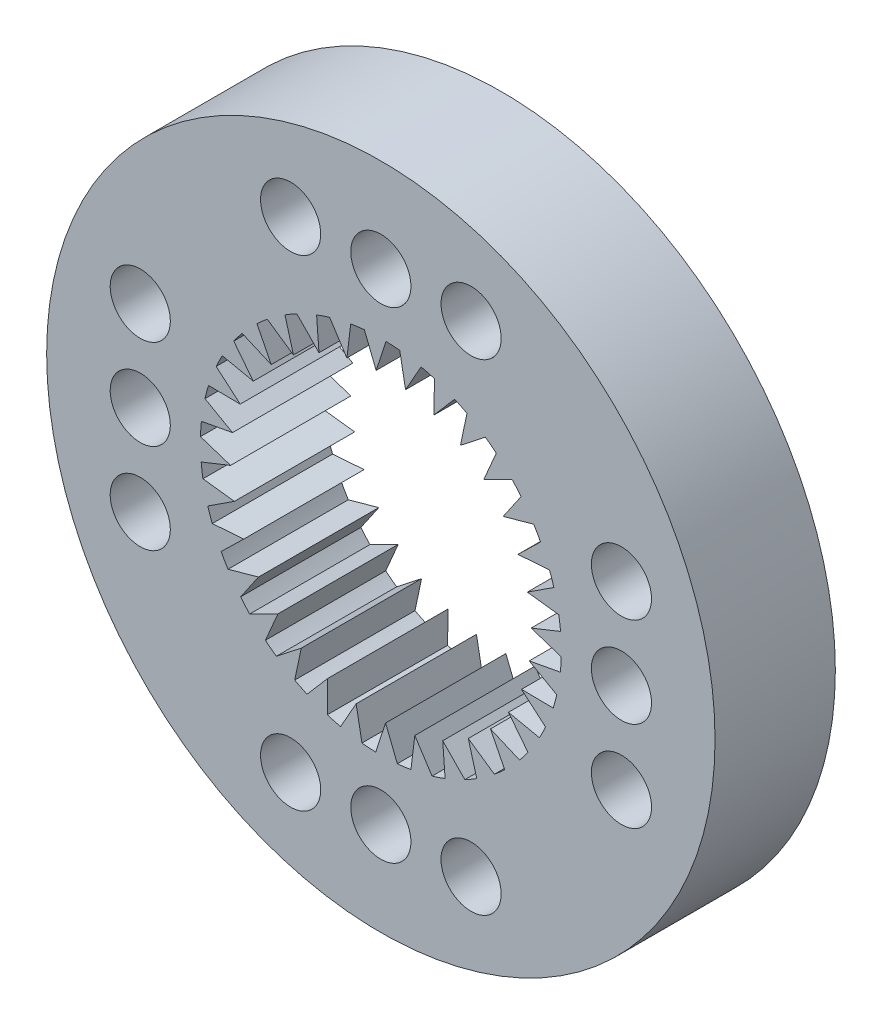
from build123d import *

# Parameters (mm, degrees)
SKETCH1_R          = 5.55625
EXTRUDE1_DEPTH     = 2
SKETCH2_R          = 0.5
CUT_EXTRUDE1_DEPTH = 2
CIRPATTERN1_COUNT  = 4
CUT_EXTRUDE2_DEPTH = 2


with BuildPart() as part:
    # Sketch1 → Extrude1 (new body)
    with BuildSketch(Plane.XY):
        Circle(SKETCH1_R)
    extrude(amount=EXTRUDE1_DEPTH)

    # Sketch2 → Cut-Extrude1 (cut)
    with BuildSketch(Plane.XY.offset(2)):
        with Locations((-1.5, 4)):
            Circle(SKETCH2_R)
        with Locations((0, 4)):
            Circle(SKETCH2_R)
        with Locations((1.5, 4)):
            Circle(SKETCH2_R)
    cut_extrude1 = extrude(amount=-CUT_EXTRUDE1_DEPTH, mode=Mode.SUBTRACT)

    # CirPattern1: Cut-Extrude1 ×4 about axis
    cirpattern1_axis = Axis((0, 0, 0), (0, 0, 1))
    for i in range(1, CIRPATTERN1_COUNT):
        add(cut_extrude1.rotate(cirpattern1_axis, i * 360 / CIRPATTERN1_COUNT), mode=Mode.SUBTRACT)

    # Sketch3 → Cut-Extrude2 (cut)
    with BuildSketch(Plane(origin=(0, 0, 0), x_dir=(-1, 0, 0), z_dir=(0, 0, -1))):
        with BuildLine():
            Line((2.655233037, -1.396330018), (2.278530277, -1.02873698))
            Line((2.278530277, -1.02873698), (2.803385583, -1.068189718))
            ThreePointArc((2.803385583, -1.068189718), (2.842070866, -0.960537971), (2.876623952, -0.85148966))
            Line((2.876623952, -0.85148966), (2.435445586, -0.564450882))
            Line((2.435445586, -0.564450882), (2.957912791, -0.500751356))
            ThreePointArc((2.957912791, -0.500751356), (2.974852933, -0.387620982), (2.987467821, -0.273927032))
            Line((2.987467821, -0.273927032), (2.498768086, -0.078473253))
            Line((2.498768086, -0.078473253), (2.998769069, 0.0859306))
            ThreePointArc((2.998769069, 0.0859306), (2.99331307, 0.200192063), (2.983504977, 0.314162459))
            Line((2.983504977, 0.314162459), (2.46606433, 0.410520059))
            Line((2.46606433, 0.410520059), (2.924384334, 0.669310291))
            ThreePointArc((2.924384334, 0.669310291), (2.896741865, 0.780311839), (2.864887711, 0.890178862))
            Line((2.864887711, 0.890178862), (2.338591105, 0.883737315))
            Line((2.338591105, 0.883737315), (2.737617149, 1.226968763))
            ThreePointArc((2.737617149, 1.226968763), (2.688850494, 1.330444669), (2.636174416, 1.431986191))
            Line((2.636174416, 1.431986191), (2.121247135, 1.322993042))
            Line((2.121247135, 1.322993042), (2.445644872, 1.737475514))
            ThreePointArc((2.445644872, 1.737475514), (2.377628107, 1.829449257), (2.306154417, 1.918763093))
            Line((2.306154417, 1.918763093), (1.822384828, 1.711406889))
            Line((1.822384828, 1.711406889), (2.059687834, 2.181212054))
            ThreePointArc((2.059687834, 2.181212054), (1.975034805, 2.258149136), (1.887510196, 2.331803006))
            Line((1.887510196, 2.331803006), (1.453489293, 2.034052328))
            Line((1.453489293, 2.034052328), (1.594578148, 2.541125839))
            ThreePointArc((1.594578148, 2.541125839), (1.496542023, 2.600069609), (1.396330018, 2.655233037))
            Line((1.396330018, 2.655233037), (1.02873698, 2.278530277))
            Line((1.02873698, 2.278530277), (1.068189718, 2.803385583))
            ThreePointArc((1.068189718, 2.803385583), (0.960537971, 2.842070866), (0.85148966, 2.876623952))
            Line((0.85148966, 2.876623952), (0.564450882, 2.435445586))
            Line((0.564450882, 2.435445586), (0.500751356, 2.957912791))
            ThreePointArc((0.500751356, 2.957912791), (0.387620982, 2.974852933), (0.273927032, 2.987467821))
            Line((0.273927032, 2.987467821), (0.078473253, 2.498768086))
            Line((0.078473253, 2.498768086), (-0.0859306, 2.998769069))
            ThreePointArc((-0.0859306, 2.998769069), (-0.200192063, 2.99331307), (-0.314162459, 2.983504977))
            Line((-0.314162459, 2.983504977), (-0.410520059, 2.46606433))
            Line((-0.410520059, 2.46606433), (-0.669310291, 2.924384334))
            ThreePointArc((-0.669310291, 2.924384334), (-0.780311839, 2.896741865), (-0.890178862, 2.864887711))
            Line((-0.890178862, 2.864887711), (-0.883737315, 2.338591105))
            Line((-0.883737315, 2.338591105), (-1.226968763, 2.737617149))
            ThreePointArc((-1.226968763, 2.737617149), (-1.330444669, 2.688850494), (-1.431986191, 2.636174416))
            Line((-1.431986191, 2.636174416), (-1.322993042, 2.121247135))
            Line((-1.322993042, 2.121247135), (-1.737475514, 2.445644872))
            ThreePointArc((-1.737475514, 2.445644872), (-1.829449257, 2.377628107), (-1.918763093, 2.306154417))
            Line((-1.918763093, 2.306154417), (-1.711406889, 1.822384828))
            Line((-1.711406889, 1.822384828), (-2.181212054, 2.059687834))
            ThreePointArc((-2.181212054, 2.059687834), (-2.258149136, 1.975034805), (-2.331803006, 1.887510196))
            Line((-2.331803006, 1.887510196), (-2.034052328, 1.453489293))
            Line((-2.034052328, 1.453489293), (-2.541125839, 1.594578148))
            ThreePointArc((-2.541125839, 1.594578148), (-2.600069609, 1.496542023), (-2.655233037, 1.396330018))
            Line((-2.655233037, 1.396330018), (-2.278530277, 1.02873698))
            Line((-2.278530277, 1.02873698), (-2.803385583, 1.068189718))
            ThreePointArc((-2.803385583, 1.068189718), (-2.842070866, 0.960537971), (-2.876623952, 0.85148966))
            Line((-2.876623952, 0.85148966), (-2.435445586, 0.564450882))
            Line((-2.435445586, 0.564450882), (-2.957912791, 0.500751356))
            ThreePointArc((-2.957912791, 0.500751356), (-2.974852933, 0.387620982), (-2.987467821, 0.273927032))
            Line((-2.987467821, 0.273927032), (-2.498768086, 0.078473253))
            Line((-2.498768086, 0.078473253), (-2.998769069, -0.0859306))
            ThreePointArc((-2.998769069, -0.0859306), (-2.99331307, -0.200192063), (-2.983504977, -0.314162459))
            Line((-2.983504977, -0.314162459), (-2.46606433, -0.410520059))
            Line((-2.46606433, -0.410520059), (-2.924384334, -0.669310291))
            ThreePointArc((-2.924384334, -0.669310291), (-2.896741865, -0.780311839), (-2.864887711, -0.890178862))
            Line((-2.864887711, -0.890178862), (-2.338591105, -0.883737315))
            Line((-2.338591105, -0.883737315), (-2.737617149, -1.226968763))
            ThreePointArc((-2.737617149, -1.226968763), (-2.688850494, -1.330444669), (-2.636174416, -1.431986191))
            Line((-2.636174416, -1.431986191), (-2.121247135, -1.322993042))
            Line((-2.121247135, -1.322993042), (-2.445644872, -1.737475514))
            ThreePointArc((-2.445644872, -1.737475514), (-2.377628107, -1.829449257), (-2.306154417, -1.918763093))
            Line((-2.306154417, -1.918763093), (-1.822384828, -1.711406889))
            Line((-1.822384828, -1.711406889), (-2.059687834, -2.181212054))
            ThreePointArc((-2.059687834, -2.181212054), (-1.975034805, -2.258149136), (-1.887510196, -2.331803006))
            Line((-1.887510196, -2.331803006), (-1.453489293, -2.034052328))
            Line((-1.453489293, -2.034052328), (-1.594578148, -2.541125839))
            ThreePointArc((-1.594578148, -2.541125839), (-1.496542023, -2.600069609), (-1.396330018, -2.655233037))
            Line((-1.396330018, -2.655233037), (-1.02873698, -2.278530277))
            Line((-1.02873698, -2.278530277), (-1.068189718, -2.803385583))
            ThreePointArc((-1.068189718, -2.803385583), (-0.960537971, -2.842070866), (-0.85148966, -2.876623952))
            Line((-0.85148966, -2.876623952), (-0.564450882, -2.435445586))
            Line((-0.564450882, -2.435445586), (-0.500751356, -2.957912791))
            ThreePointArc((-0.500751356, -2.957912791), (-0.387620982, -2.974852933), (-0.273927032, -2.987467821))
            Line((-0.273927032, -2.987467821), (-0.078473253, -2.498768086))
            Line((-0.078473253, -2.498768086), (0.0859306, -2.998769069))
            ThreePointArc((0.0859306, -2.998769069), (0.200192063, -2.99331307), (0.314162459, -2.983504977))
            Line((0.314162459, -2.983504977), (0.410520059, -2.46606433))
            Line((0.410520059, -2.46606433), (0.669310291, -2.924384334))
            ThreePointArc((0.669310291, -2.924384334), (0.780311839, -2.896741865), (0.890178862, -2.864887711))
            Line((0.890178862, -2.864887711), (0.883737315, -2.338591105))
            Line((0.883737315, -2.338591105), (1.226968763, -2.737617149))
            ThreePointArc((1.226968763, -2.737617149), (1.330444669, -2.688850494), (1.431986191, -2.636174416))
            Line((1.431986191, -2.636174416), (1.322993042, -2.121247135))
            Line((1.322993042, -2.121247135), (1.737475514, -2.445644872))
            ThreePointArc((1.737475514, -2.445644872), (1.829449257, -2.377628107), (1.918763093, -2.306154417))
            Line((1.918763093, -2.306154417), (1.711406889, -1.822384828))
            Line((1.711406889, -1.822384828), (2.181212054, -2.059687834))
            ThreePointArc((2.181212054, -2.059687834), (2.258149136, -1.975034805), (2.331803006, -1.887510196))
            Line((2.331803006, -1.887510196), (2.034052328, -1.453489293))
            Line((2.034052328, -1.453489293), (2.541125839, -1.594578148))
            ThreePointArc((2.541125839, -1.594578148), (2.600069609, -1.496542023), (2.655233037, -1.396330018))
        make_face()
    extrude(amount=-CUT_EXTRUDE2_DEPTH, mode=Mode.SUBTRACT)


solid = part.part
